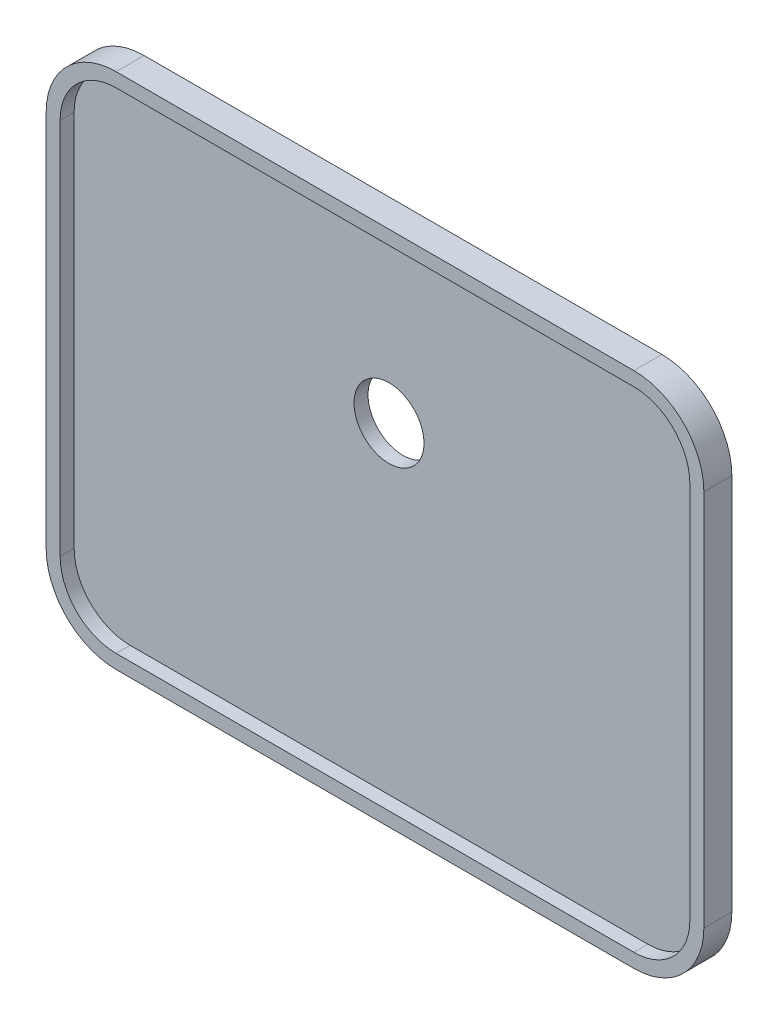
from build123d import *

# Parameters (mm, degrees)
AUFSATZ_LINEAR_AUSTRAGEN1_DEPTH = 20
AUFSATZ_LINEAR_AUSTRAGEN2_DEPTH = 10
SKIZZE3_R                       = 25
SCHNITT_LINEAR_AUSTRAGEN1_DEPTH = 15


with BuildPart() as part:
    # Skizze1 → Aufsatz-Linear austragen1 (new body)
    with BuildSketch(Plane.XY):
        with BuildLine():
            Line((-0.330334949, 95.09360025), (369.669665051, 95.09360025))
            ThreePointArc((369.669665051, 95.09360025), (405.02500411, 80.448939309), (419.669665051, 45.09360025))
            Line((419.669665051, 45.09360025), (419.669665051, -224.90639975))
            ThreePointArc((419.669665051, -224.90639975), (405.02500411, -260.26173881), (369.669665051, -274.90639975))
            Line((369.669665051, -274.90639975), (-0.330334949, -274.90639975))
            ThreePointArc((-0.330334949, -274.90639975), (-35.685674008, -260.26173881), (-50.330334949, -224.90639975))
            Line((-50.330334949, -224.90639975), (-50.330334949, 45.09360025))
            ThreePointArc((-50.330334949, 45.09360025), (-35.685674008, 80.448939309), (-0.330334949, 95.09360025))
        make_face()
        with BuildLine():
            Line((-0.330334949, 85.09360025), (369.669665051, 85.09360025))
            ThreePointArc((369.669665051, 85.09360025), (397.953936298, 73.377871497), (409.669665051, 45.09360025))
            Line((409.669665051, 45.09360025), (409.669665051, -224.90639975))
            ThreePointArc((409.669665051, -224.90639975), (397.953936298, -253.190670998), (369.669665051, -264.90639975))
            Line((369.669665051, -264.90639975), (-0.330334949, -264.90639975))
            ThreePointArc((-0.330334949, -264.90639975), (-28.614606196, -253.190670998), (-40.330334949, -224.90639975))
            Line((-40.330334949, -224.90639975), (-40.330334949, 45.09360025))
            ThreePointArc((-40.330334949, 45.09360025), (-28.614606196, 73.377871497), (-0.330334949, 85.09360025))
        make_face(mode=Mode.SUBTRACT)
    extrude(amount=AUFSATZ_LINEAR_AUSTRAGEN1_DEPTH)

    # Skizze2 → Aufsatz-Linear austragen2 (add)
    with BuildSketch(Plane.XY):
        with BuildLine():
            Line((-0.330334949, -264.90639975), (369.669665051, -264.90639975))
            ThreePointArc((369.669665051, -264.90639975), (397.953936298, -253.190670998), (409.669665051, -224.90639975))
            Line((409.669665051, -224.90639975), (409.669665051, 45.09360025))
            ThreePointArc((409.669665051, 45.09360025), (397.953936298, 73.377871497), (369.669665051, 85.09360025))
            Line((369.669665051, 85.09360025), (-0.330334949, 85.09360025))
            ThreePointArc((-0.330334949, 85.09360025), (-28.614606196, 73.377871497), (-40.330334949, 45.09360025))
            Line((-40.330334949, 45.09360025), (-40.330334949, -224.90639975))
            ThreePointArc((-40.330334949, -224.90639975), (-28.614606196, -253.190670998), (-0.330334949, -264.90639975))
        make_face()
    extrude(amount=AUFSATZ_LINEAR_AUSTRAGEN2_DEPTH)

    # Skizze3 → Schnitt-Linear austragen1 (cut)
    with BuildSketch(Plane.XY):
        with Locations((184.669665051, -34.90639975)):
            Circle(SKIZZE3_R)
    extrude(amount=SCHNITT_LINEAR_AUSTRAGEN1_DEPTH, mode=Mode.SUBTRACT)


solid = part.part
